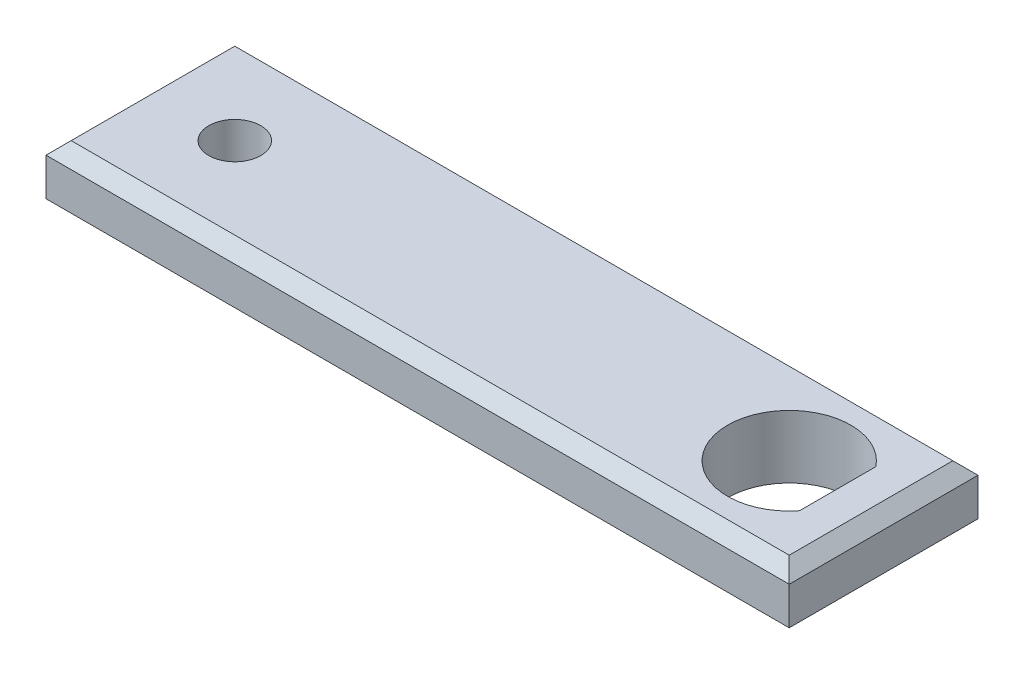
from build123d import *

# Parameters (mm, degrees)
SKETCH1_W          = 75
SKETCH1_H          = 6.35
BASE_EXTRUDE_DEPTH = 19.05
CUT_EXTRUDE1_DEPTH = 7.35
SKETCH3_R          = 2.622460094
CUT_EXTRUDE2_DEPTH = 7.35
CHAMFER1_SIZE      = 1.27


with BuildPart() as part:
    # Sketch1 → Base-Extrude (new body)
    with BuildSketch(Plane.XY):
        with Locations((37.5, 3.175)):
            Rectangle(SKETCH1_W, SKETCH1_H)
    extrude(amount=BASE_EXTRUDE_DEPTH)

    # Sketch2 → Cut-Extrude1 (cut, through all)
    with BuildSketch(Plane(origin=(0, 6.35, 0), x_dir=(-1, 0, 0), z_dir=(0, 1, 0))):
        with BuildLine():
            Line((-70.3645, 5.67551708), (-70.3645, 13.37448292))
            ThreePointArc((-70.3645, 13.37448292), (-59.252, 9.525), (-70.3645, 5.67551708))
        make_face()
    extrude(amount=-CUT_EXTRUDE1_DEPTH, mode=Mode.SUBTRACT)

    # Sketch3 → Cut-Extrude2 (cut, through all)
    with BuildSketch(Plane(origin=(0, 6.35, 0), x_dir=(-1, 0, 0), z_dir=(0, 1, 0))):
        with Locations((-9.525, 9.525)):
            Circle(SKETCH3_R)
    extrude(amount=-CUT_EXTRUDE2_DEPTH, mode=Mode.SUBTRACT)

    # Chamfer1
    chamfer1_edges = [part.edges().sort_by_distance(p)[0] for p in [
        (37.5, 0, 19.05),
        (37.5, 0, 0),
        (37.5, 6.35, 0),
        (37.5, 6.35, 19.05),
        (0, 0, 9.525),
        (75, 0, 9.525),
        (75, 6.35, 9.525),
        (0, 6.35, 9.525),
    ]]
    chamfer(chamfer1_edges, length=CHAMFER1_SIZE)


solid = part.part
